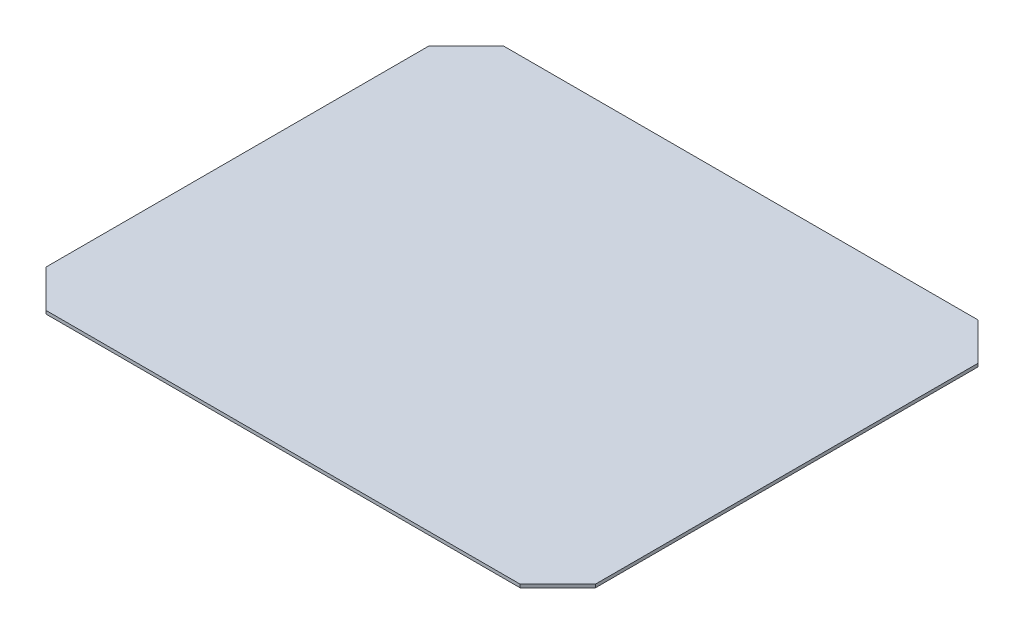
from build123d import *

# Parameters (mm, degrees)
BOSS_EXTRUDE1_DEPTH = 3.5
CUT_EXTRUDE1_DEPTH  = 4.5


with BuildPart() as part:
    # Sketch1 → Boss-Extrude1 (new body)
    with BuildSketch(Plane(origin=(0, 0, 0), x_dir=(1, 0, 0), z_dir=(0, 1, 0))):
        Polygon((-280, 230), (260, 230), (280, 230), (280, 210), (280, -250), (280, -270), (260, -270), (-280, -270), (-320, -270), (-320, -250), (-320, 210), (-320, 230), align=None)
    extrude(amount=BOSS_EXTRUDE1_DEPTH)

    # Sketch2 → Cut-Extrude1 (cut, through all)
    with BuildSketch(Plane(origin=(0, 3.5, 0), x_dir=(1, 0, 0), z_dir=(0, 1, 0))):
        Polygon((-320, -229), (-320, -270), (-279, -270), align=None)
        Polygon((-320, 230), (-279, 230), (-320, 189), align=None)
        Polygon((280, -270), (239, -270), (280, -229), align=None)
        Polygon((280, 189), (280, 230), (239, 230), align=None)
    extrude(amount=-CUT_EXTRUDE1_DEPTH, mode=Mode.SUBTRACT)


solid = part.part
